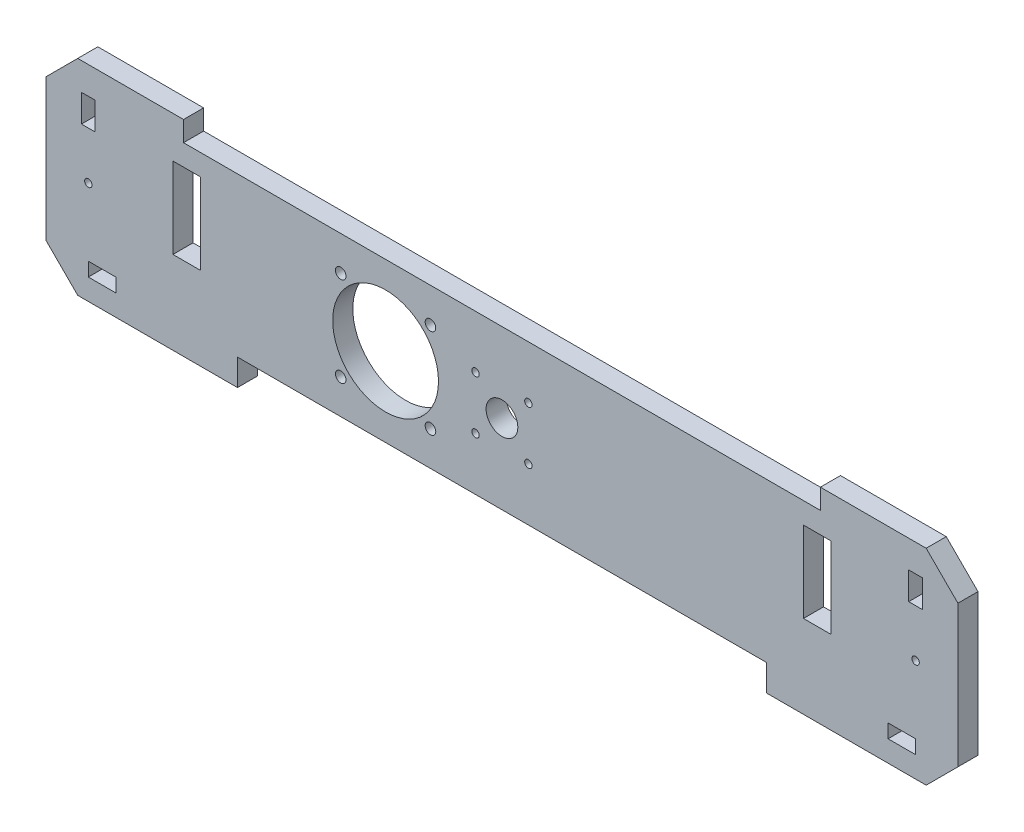
from build123d import *

# Parameters (mm, degrees)
CROQUIS1_R              = 3.5
CROQUIS1_R_2            = 15
CROQUIS1_R_3            = 50
CROQUIS1_R_4            = 5
CROQUIS1_W              = 26
CROQUIS1_H              = 76.5
CROQUIS1_H_2            = 13
CROQUIS1_W_2            = 13
CROQUIS1_H_3            = 26
SALIENTE_EXTRUIR1_DEPTH = 19


with BuildPart() as part:
    # Croquis1 → Saliente-Extruir1 (new body)
    with BuildSketch(Plane.XY):
        Polygon((-301, 194), (-301, 175), (301, 175), (301, 194), (401, 194), (431, 164), (431, 30), (401, 0), (250, 0), (250, 25), (-250, 25), (-250, 0), (-401, 0), (-431, 30), (-431, 164), (-401, 194), align=None)
        with Locations((-391, 97)):
            Circle(CROQUIS1_R, mode=Mode.SUBTRACT)
        with Locations((391, 97)):
            Circle(CROQUIS1_R, mode=Mode.SUBTRACT)
        with Locations((0, 100)):
            Circle(CROQUIS1_R_2, mode=Mode.SUBTRACT)
        with Locations((-25, 125)):
            Circle(CROQUIS1_R, mode=Mode.SUBTRACT)
        with Locations((25, 125)):
            Circle(CROQUIS1_R, mode=Mode.SUBTRACT)
        with Locations((25, 75)):
            Circle(CROQUIS1_R, mode=Mode.SUBTRACT)
        with Locations((-25, 75)):
            Circle(CROQUIS1_R, mode=Mode.SUBTRACT)
        with Locations((-110, 100)):
            Circle(CROQUIS1_R_3, mode=Mode.SUBTRACT)
        with Locations((-152.426406871, 142.426406871)):
            Circle(CROQUIS1_R_4, mode=Mode.SUBTRACT)
        with Locations((-67.573593129, 142.426406871)):
            Circle(CROQUIS1_R_4, mode=Mode.SUBTRACT)
        with Locations((-67.573593129, 57.573593129)):
            Circle(CROQUIS1_R_4, mode=Mode.SUBTRACT)
        with Locations((-152.426406871, 57.573593129)):
            Circle(CROQUIS1_R_4, mode=Mode.SUBTRACT)
        with Locations((-298, 116.75)):
            Rectangle(CROQUIS1_W, CROQUIS1_H, mode=Mode.SUBTRACT)
        with Locations((298, 116.75)):
            Rectangle(CROQUIS1_W, CROQUIS1_H, mode=Mode.SUBTRACT)
        with Locations((378, 26.5)):
            Rectangle(CROQUIS1_W, CROQUIS1_H_2, mode=Mode.SUBTRACT)
        with Locations((-378, 26.5)):
            Rectangle(CROQUIS1_W, CROQUIS1_H_2, mode=Mode.SUBTRACT)
        with Locations((391, 155)):
            Rectangle(CROQUIS1_W_2, CROQUIS1_H_3, mode=Mode.SUBTRACT)
        with Locations((-391, 155)):
            Rectangle(CROQUIS1_W_2, CROQUIS1_H_3, mode=Mode.SUBTRACT)
    extrude(amount=SALIENTE_EXTRUIR1_DEPTH)


solid = part.part
